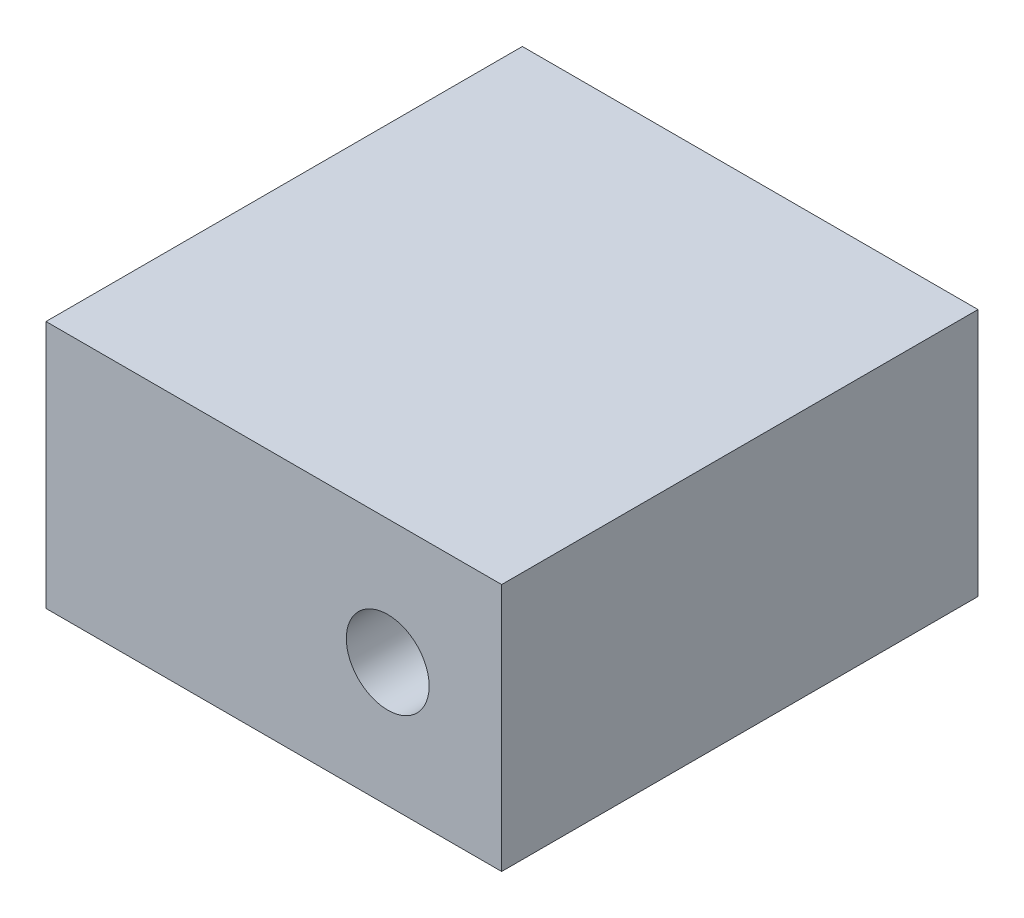
from build123d import *

# Parameters (mm, degrees)
SKETCH1_W           = 22
SKETCH1_H           = 12
BOSS_EXTRUDE1_DEPTH = 23
SKETCH2_R           = 2
CUT_EXTRUDE1_DEPTH  = 11


with BuildPart() as part:
    # Sketch1 → Boss-Extrude1 (new body)
    with BuildSketch(Plane.XY):
        with Locations((11, 6)):
            Rectangle(SKETCH1_W, SKETCH1_H)
    extrude(amount=BOSS_EXTRUDE1_DEPTH)

    # Sketch2 → Cut-Extrude1 (cut)
    with BuildSketch(Plane.XY.offset(23)):
        with Locations((16.5, 6)):
            Circle(SKETCH2_R)
    extrude(amount=-CUT_EXTRUDE1_DEPTH, mode=Mode.SUBTRACT)


solid = part.part
